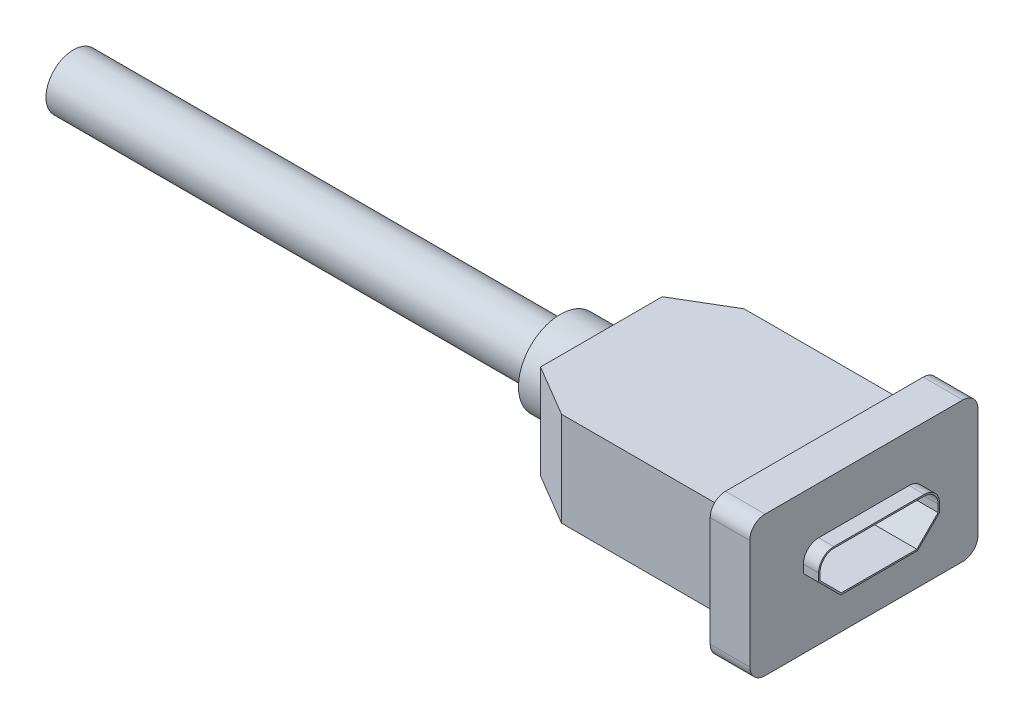
from build123d import *

# Parameters (mm, degrees)
BOSS_EXTRUDE1_DEPTH = 3.1
SKETCH2_W           = 15
SKETCH2_H           = 9.2
BOSS_EXTRUDE2_DEPTH = 2.6
SKETCH3_R           = 2.75
BOSS_EXTRUDE3_DEPTH = 2.7
SKETCH4_R           = 1.8
BOSS_EXTRUDE4_DEPTH = 32
FILLET1_R           = 1
CUT_EXTRUDE1_DEPTH  = 7
BOSS_EXTRUDE5_DEPTH = 1


with BuildPart() as part:
    # Sketch1 → Boss-Extrude1 (new body, symmetric)
    with BuildSketch(Plane(origin=(0, 0, 0), x_dir=(1, 0, 0), z_dir=(0, 1, 0))):
        Polygon((0, 6), (0, -6), (-13.87, -6), (-17.25, -4), (-17.25, 4), (-13.87, 6), align=None)
    extrude(amount=BOSS_EXTRUDE1_DEPTH, both=True)

    # Sketch2 → Boss-Extrude2 (add)
    with BuildSketch(Plane(origin=(0, 0, 0), x_dir=(0, 0, -1), z_dir=(1, 0, 0))):
        Rectangle(SKETCH2_W, SKETCH2_H)
    extrude(amount=-BOSS_EXTRUDE2_DEPTH)

    # Sketch3 → Boss-Extrude3 (add)
    with BuildSketch(Plane.ZY.offset(17.25)):
        Circle(SKETCH3_R)
    extrude(amount=BOSS_EXTRUDE3_DEPTH)

    # Sketch4 → Boss-Extrude4 (add)
    with BuildSketch(Plane.ZY.offset(19.95)):
        Circle(SKETCH4_R)
    extrude(amount=BOSS_EXTRUDE4_DEPTH)

    # Fillet1
    fillet1_edges = [part.edges().sort_by_distance(p)[0] for p in [
        (-1.3, -4.6, 7.5),
        (-1.3, 4.6, 7.5),
        (-1.3, 4.6, -7.5),
        (-1.3, -4.6, -7.5),
    ]]
    fillet(fillet1_edges, radius=FILLET1_R)

    # Sketch5 → Cut-Extrude1 (cut)
    with BuildSketch(Plane(origin=(0, 0, 0), x_dir=(0, 0, -1), z_dir=(1, 0, 0))):
        with BuildLine():
            Line((2.975, 1.39), (-2.975, 1.39))
            ThreePointArc((-2.975, 1.39), (-3.611396103, 1.126396103), (-3.875, 0.49))
            Line((-3.875, 0.49), (-3.875, 0))
            Line((-3.875, 0), (-2.485, -1.39))
            Line((-2.485, -1.39), (2.485, -1.39))
            Line((2.485, -1.39), (3.875, 0))
            Line((3.875, 0), (3.875, 0.49))
            ThreePointArc((3.875, 0.49), (3.611396103, 1.126396103), (2.975, 1.39))
        make_face()
    extrude(amount=-CUT_EXTRUDE1_DEPTH, mode=Mode.SUBTRACT)

    # Sketch7 → Boss-Extrude5 (add)
    with BuildSketch(Plane(origin=(0, 0, 0), x_dir=(0, 0, -1), z_dir=(1, 0, 0))):
        with BuildLine():
            Line((2.975, 1.49), (-2.975, 1.49))
            ThreePointArc((-2.975, 1.49), (-3.682106781, 1.197106781), (-3.975, 0.49))
            Line((-3.975, 0.49), (-3.975, -0.041421356))
            Line((-3.975, -0.041421356), (-2.526421356, -1.49))
            Line((-2.526421356, -1.49), (2.526421356, -1.49))
            Line((2.526421356, -1.49), (3.975, -0.041421356))
            Line((3.975, -0.041421356), (3.975, 0.49))
            ThreePointArc((3.975, 0.49), (3.682106781, 1.197106781), (2.975, 1.49))
        make_face()
        with BuildLine():
            Line((-3.875, 0.49), (-3.875, 0))
            Line((-3.875, 0), (-2.485, -1.39))
            Line((-2.485, -1.39), (2.485, -1.39))
            Line((2.485, -1.39), (3.875, 0))
            Line((3.875, 0), (3.875, 0.49))
            ThreePointArc((3.875, 0.49), (3.611396103, 1.126396103), (2.975, 1.39))
            Line((2.975, 1.39), (-2.975, 1.39))
            ThreePointArc((-2.975, 1.39), (-3.611396103, 1.126396103), (-3.875, 0.49))
        make_face(mode=Mode.SUBTRACT)
    extrude(amount=BOSS_EXTRUDE5_DEPTH)


solid = part.part
